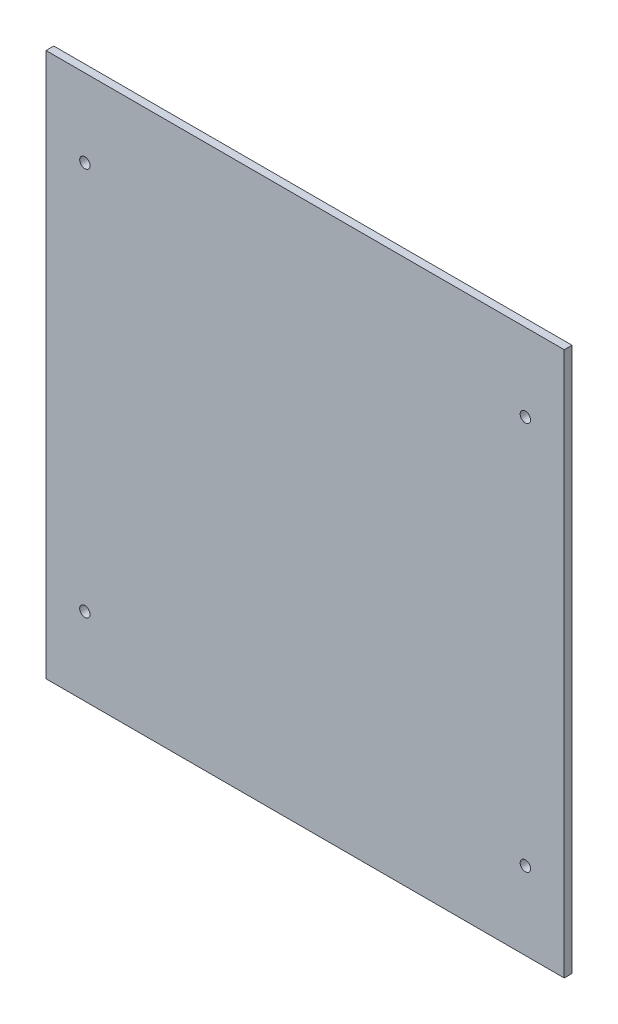
from build123d import *

# Parameters (mm, degrees)
SKETCH1_W           = 200
SKETCH1_H           = 210
BOSS_EXTRUDE1_DEPTH = 3
SKETCH2_R           = 2
CUT_EXTRUDE1_DEPTH  = 100


with BuildPart() as part:
    # Sketch1 → Boss-Extrude1 (new body)
    with BuildSketch(Plane.XY):
        with Locations((100, 105)):
            Rectangle(SKETCH1_W, SKETCH1_H)
    extrude(amount=BOSS_EXTRUDE1_DEPTH)

    # Sketch2 → Cut-Extrude1 (cut)
    with BuildSketch(Plane(origin=(0, 0, 0), x_dir=(-1, 0, 0), z_dir=(0, 0, -1))):
        with Locations((-185, 180)):
            Circle(SKETCH2_R)
        with Locations((-185, 30)):
            Circle(SKETCH2_R)
        with Locations((-15, 30)):
            Circle(SKETCH2_R)
        with Locations((-15, 180)):
            Circle(SKETCH2_R)
    extrude(amount=-CUT_EXTRUDE1_DEPTH, mode=Mode.SUBTRACT)


solid = part.part
